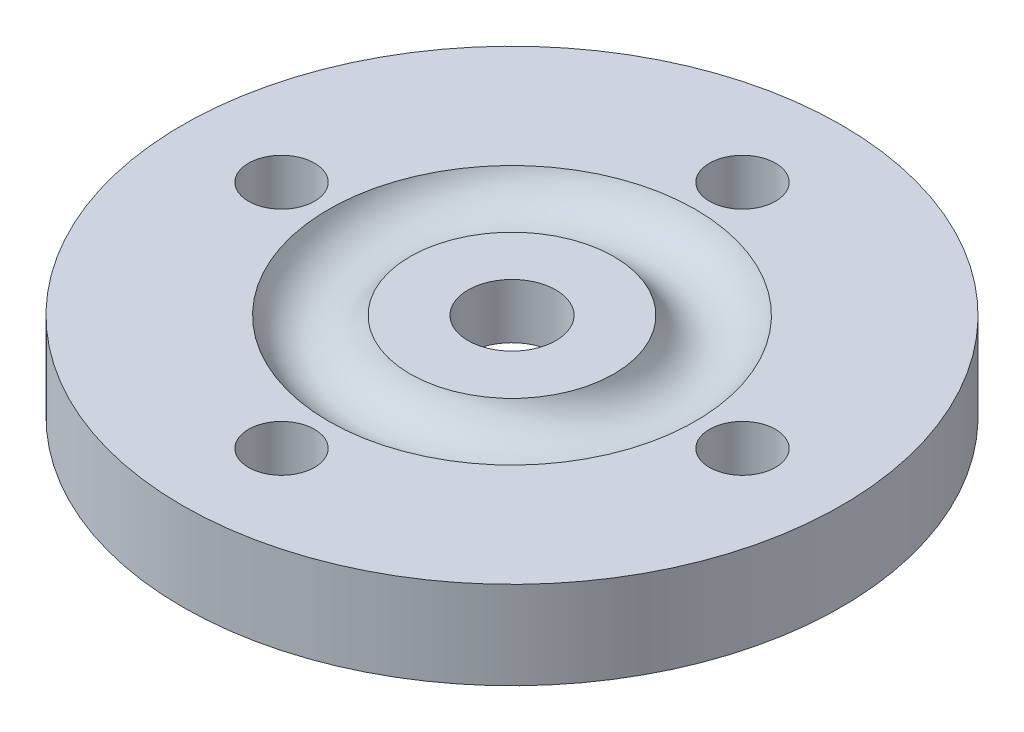
from build123d import *

# Parameters (mm, degrees)
SKETCH1_R          = 11.9126
SKETCH1_R_2        = 1.1938
SKETCH1_R_3        = 6.7437
SKETCH1_R_4        = 5.1562
SKETCH1_R_5        = 3.5687
SKETCH1_R_6        = 1.5875
EXTRUDE1_DEPTH     = 3.175
SKETCH3_R          = 1.5875
CUT_EXTRUDE1_START = -1.9812
SKETCH1_3_R        = 3.5687
SKETCH1_3_R_2      = 1.5875
CUT_EXTRUDE1_DEPTH = 3.175
SKETCH1_4_R        = 1.5875
CUT_EXTRUDE2_DEPTH = 3.175


with BuildPart() as part:
    # Sketch1 → Extrude1 (new body)
    with BuildSketch(Plane(origin=(0, 0, 0), x_dir=(1, 0, 0), z_dir=(0, 1, 0))):
        with Locations(Location((0, 0, 0), (0, 0, 270))):  # turned: the seam where the file's is
            Circle(SKETCH1_R)
        with Locations(Location((-8.3312, 0, 0), (0, 0, 270))):  # turned: the seam where the file's is
            Circle(SKETCH1_R_2, mode=Mode.SUBTRACT)
        with Locations(Location((0, -8.3312, 0), (0, 0, 270))):  # turned: the seam where the file's is
            Circle(SKETCH1_R_2, mode=Mode.SUBTRACT)
        with Locations(Location((8.3312, 0, 0), (0, 0, 270))):  # turned: the seam where the file's is
            Circle(SKETCH1_R_2, mode=Mode.SUBTRACT)
        with Locations(Location((0, 8.3312, 0), (0, 0, 270))):  # turned: the seam where the file's is
            Circle(SKETCH1_R_2, mode=Mode.SUBTRACT)
        Circle(SKETCH1_R_3, mode=Mode.SUBTRACT)
        Circle(SKETCH1_R_3)
        Circle(SKETCH1_R_4, mode=Mode.SUBTRACT)
        Circle(SKETCH1_R_4)
        Circle(SKETCH1_R_5, mode=Mode.SUBTRACT)
        Circle(SKETCH1_R_5)
        Circle(SKETCH1_R_6, mode=Mode.SUBTRACT)
        Circle(SKETCH1_R_6)
    extrude(amount=-EXTRUDE1_DEPTH)

    # Sketch3 → Cut-Revolve1 (revolve, cut)
    with BuildSketch(Plane.XY, mode=Mode.PRIVATE) as cut_revolve1_sk:
        with Locations((5.1562, 0.5842)):
            Circle(SKETCH3_R)
    revolve(cut_revolve1_sk.sketch.rotate(Axis((0, 5.548517396, 0), (0, -1, 0)), 90), axis=Axis((0, 5.548517396, 0), (0, -1, 0)), mode=Mode.SUBTRACT)  # turned: the seam where the file's is

    # Sketch1_3 → Cut-Extrude1 (cut)
    with BuildSketch(Plane(origin=(0, 0, 0), x_dir=(1, 0, 0), z_dir=(0, 1, 0)).offset(CUT_EXTRUDE1_START)):
        with Locations(Location((0, 0, 0), (0, 0, 270))):  # turned: the seam where the file's is
            Circle(SKETCH1_3_R)
        Circle(SKETCH1_3_R_2, mode=Mode.SUBTRACT)
        Circle(SKETCH1_3_R_2)
    extrude(amount=-CUT_EXTRUDE1_DEPTH, mode=Mode.SUBTRACT)

    # Sketch1_4 → Cut-Extrude2 (cut)
    with BuildSketch(Plane(origin=(0, 0, 0), x_dir=(1, 0, 0), z_dir=(0, 1, 0))):
        with Locations(Location((0, 0, 0), (0, 0, 270))):  # turned: the seam where the file's is
            Circle(SKETCH1_4_R)
    extrude(amount=-CUT_EXTRUDE2_DEPTH, mode=Mode.SUBTRACT)


solid = part.part
